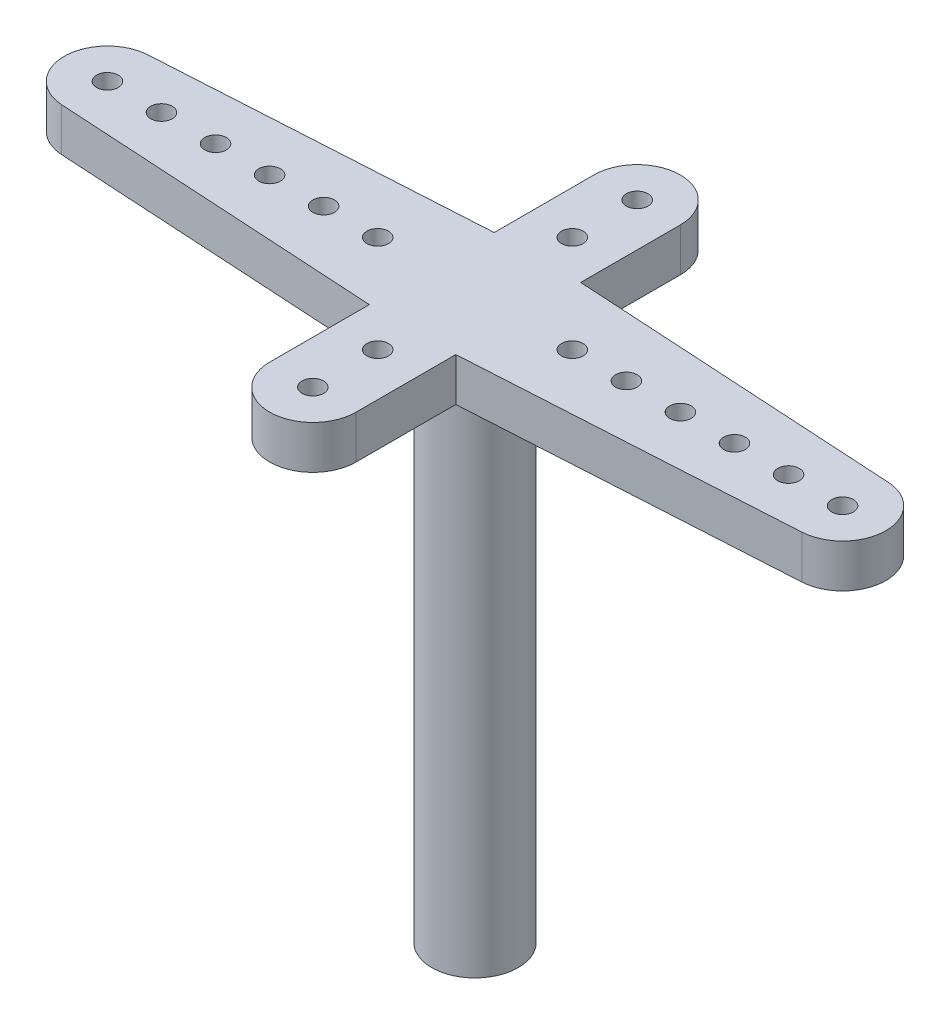
from build123d import *

# Parameters (mm, degrees)
SKETCH1_R           = 2
SKETCH1_R_2         = 0.5
BOSS_EXTRUDE1_DEPTH = 2
BOSS_EXTRUDE2_START = 2
SKETCH1_3_R         = 2
BOSS_EXTRUDE2_DEPTH = 26


with BuildPart() as part:
    # Sketch1 → Boss-Extrude1 (new body)
    with BuildSketch(Plane(origin=(0, 0, 0), x_dir=(1, 0, 0), z_dir=(0, 1, 0))):
        with BuildLine():
            Line((2, 7.5), (2, 2.88735269))
            Line((2, 2.88735269), (17.117647059, 1.996536794))
            ThreePointArc((17.117647059, 1.996536794), (19, 0), (17.117647059, -1.996536794))
            Line((17.117647059, -1.996536794), (2, -2.88735269))
            Line((2, -2.88735269), (2, -7.5))
            ThreePointArc((2, -7.5), (0, -9.5), (-2, -7.5))
            Line((-2, -7.5), (-2, -2.88735269))
            Line((-2, -2.88735269), (-17.117647059, -1.996536794))
            ThreePointArc((-17.117647059, -1.996536794), (-19, 0), (-17.117647059, 1.996536794))
            Line((-17.117647059, 1.996536794), (-2, 2.88735269))
            Line((-2, 2.88735269), (-2, 7.5))
            ThreePointArc((-2, 7.5), (0, 9.5), (2, 7.5))
        make_face()
        Circle(SKETCH1_R, mode=Mode.SUBTRACT)
        with Locations((-17, 0)):
            Circle(SKETCH1_R_2, mode=Mode.SUBTRACT)
        with Locations((17, 0)):
            Circle(SKETCH1_R_2, mode=Mode.SUBTRACT)
        with Locations((-14.5, 0)):
            Circle(SKETCH1_R_2, mode=Mode.SUBTRACT)
        with Locations((-12, 0)):
            Circle(SKETCH1_R_2, mode=Mode.SUBTRACT)
        with Locations((-9.5, 0)):
            Circle(SKETCH1_R_2, mode=Mode.SUBTRACT)
        with Locations((-7, 0)):
            Circle(SKETCH1_R_2, mode=Mode.SUBTRACT)
        with Locations((-4.5, 0)):
            Circle(SKETCH1_R_2, mode=Mode.SUBTRACT)
        with Locations((4.5, 0)):
            Circle(SKETCH1_R_2, mode=Mode.SUBTRACT)
        with Locations((7, 0)):
            Circle(SKETCH1_R_2, mode=Mode.SUBTRACT)
        with Locations((9.5, 0)):
            Circle(SKETCH1_R_2, mode=Mode.SUBTRACT)
        with Locations((12, 0)):
            Circle(SKETCH1_R_2, mode=Mode.SUBTRACT)
        with Locations((14.5, 0)):
            Circle(SKETCH1_R_2, mode=Mode.SUBTRACT)
        with Locations((0, 7.5)):
            Circle(SKETCH1_R_2, mode=Mode.SUBTRACT)
        with Locations((0, 4.5)):
            Circle(SKETCH1_R_2, mode=Mode.SUBTRACT)
        with Locations((0, -4.5)):
            Circle(SKETCH1_R_2, mode=Mode.SUBTRACT)
        with Locations((0, -7.5)):
            Circle(SKETCH1_R_2, mode=Mode.SUBTRACT)
    extrude(amount=BOSS_EXTRUDE1_DEPTH)

    # Sketch1_3 → Boss-Extrude2 (add)
    with BuildSketch(Plane(origin=(0, 0, 0), x_dir=(1, 0, 0), z_dir=(0, 1, 0)).offset(BOSS_EXTRUDE2_START)):
        Circle(SKETCH1_3_R)
    extrude(amount=-BOSS_EXTRUDE2_DEPTH)


solid = part.part
